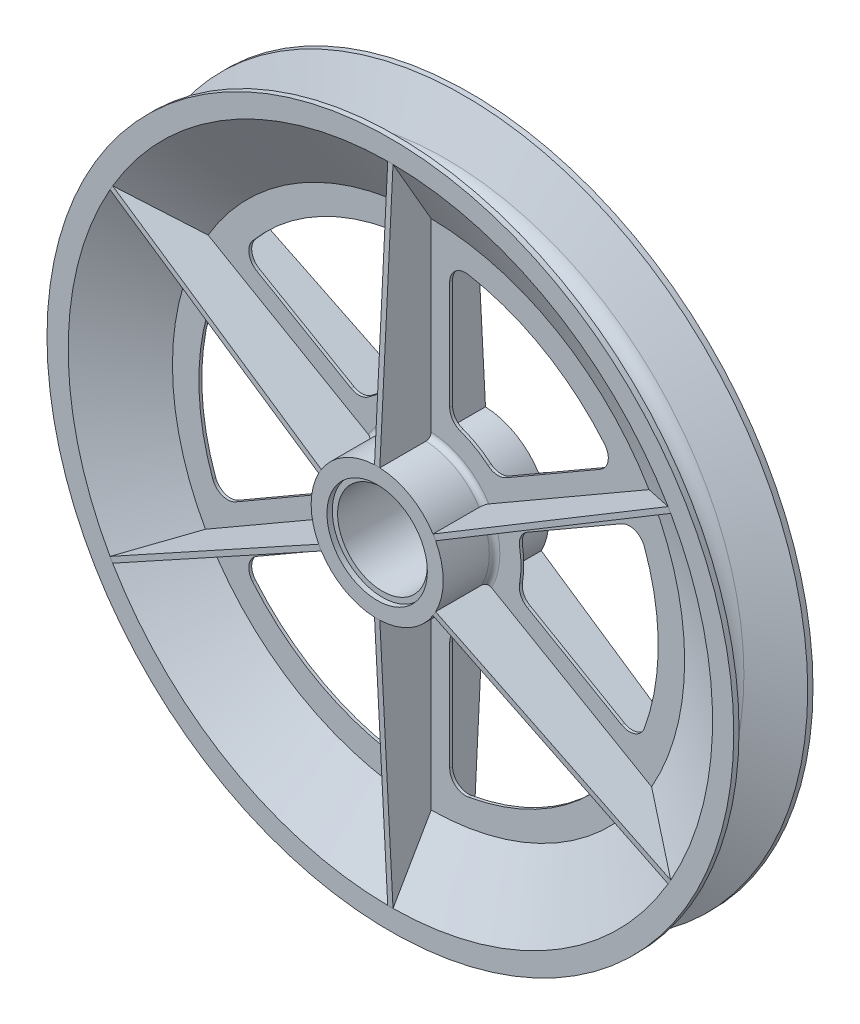
from build123d import *

# Parameters (mm, degrees)
SKETCH1_R            = 650
BOSS_EXTRUDE1_DEPTH  = 75
SKETCH2_R            = 480
CUT_EXTRUDE1_DEPTH   = 76
CUT_EXTRUDE1_TAPER   = -60
SKETCH3_R            = 125
BOSS_EXTRUDE2_DEPTH  = 100
SKETCH4_R            = 95
CUT_EXTRUDE2_DEPTH   = 10
SKETCH5_R            = 85
CUT_EXTRUDE3_DEPTH   = 201
SKETCH6_R            = 485
SKETCH6_R_2          = 85
BOSS_EXTRUDE3_DEPTH  = 2.75
FILLET1_R            = 10
CUT_EXTRUDE4_DEPTH   = 101
CIRPATTERN1_COUNT    = 6
BOSS_EXTRUDE4_DEPTH  = 5
CIRPATTERN2_COUNT    = 6
MIRROR3_COPY_1_DEPTH = 5
MIRROR3_COPY_2_DEPTH = 5
MIRROR3_COPY_3_DEPTH = 5
MIRROR3_COPY_4_DEPTH = 5
MIRROR3_COPY_5_DEPTH = 5
SCALE2_SCALE         = 0.035294118


with BuildPart() as part:
    # Sketch1 → Boss-Extrude1 (new body, symmetric)
    with BuildSketch(Plane.XY):
        Circle(SKETCH1_R)
    extrude(amount=BOSS_EXTRUDE1_DEPTH, both=True)

    # Sketch2 → Cut-Extrude1 (cut, through all)
    with BuildSketch(Plane.XY):
        Circle(SKETCH2_R)
    cut_extrude1 = extrude(amount=-CUT_EXTRUDE1_DEPTH, taper=CUT_EXTRUDE1_TAPER, mode=Mode.SUBTRACT)

    # Mirror1: Cut-Extrude1 across plane
    add(cut_extrude1.mirror(Plane.XY), mode=Mode.SUBTRACT)



with BuildPart() as body_2:
    # Sketch3 → Boss-Extrude2 (new body, symmetric)
    with BuildSketch(Plane.XY):
        Circle(SKETCH3_R)
    extrude(amount=BOSS_EXTRUDE2_DEPTH, both=True)

    # Sketch4 → Cut-Extrude2 (cut)
    with BuildSketch(Plane.XY.offset(100)):
        Circle(SKETCH4_R)
    cut_extrude2 = extrude(amount=-CUT_EXTRUDE2_DEPTH, mode=Mode.SUBTRACT)

    # Mirror2: Cut-Extrude2 across plane
    add(cut_extrude2.mirror(Plane.XY), mode=Mode.SUBTRACT)

    # Sketch5 → Cut-Extrude3 (cut, through all)
    with BuildSketch(Plane.XY.offset(100)):
        Circle(SKETCH5_R)
    extrude(amount=-CUT_EXTRUDE3_DEPTH, mode=Mode.SUBTRACT)


with BuildPart() as part_1:
    add(part.part)

    add(body_2.part)  # Boss-Extrude3 merges body 2
    # Sketch6 → Boss-Extrude3 (add, symmetric)
    with BuildSketch(Plane.XY):
        Circle(SKETCH6_R)
        Circle(SKETCH6_R_2, mode=Mode.SUBTRACT)
    extrude(amount=BOSS_EXTRUDE3_DEPTH, both=True)

    # Fillet1
    fillet1_edges = [part_1.edges().sort_by_distance(p)[0] for p in [
        (-125, 0, -2.75),
        (-125, 0, 2.75),
    ]]
    fillet(fillet1_edges, radius=FILLET1_R)

    # Sketch7 → Cut-Extrude4 (cut, symmetric)
    with BuildSketch(Plane.XY):
        with BuildLine():
            Line((40, 398.664268874), (40, 192.67848868))
            ThreePointArc((40, 192.67848868), (45.430536502, 175.463917427), (59.756097561, 164.481636678))
            ThreePointArc((59.756097561, 164.481636678), (87.5, 151.554445662), (112.567227039, 133.991116858))
            ThreePointArc((112.567227039, 133.991116858), (129.240941689, 127.075957432), (146.86446596, 130.980260491))
            Line((146.86446596, 130.980260491), (325.253384426, 233.973150588))
            ThreePointArc((325.253384426, 233.973150588), (339.795743882, 254.733855447), (333.248565111, 279.22102627))
            ThreePointArc((333.248565111, 279.22102627), (217.38156986, 376.515923627), (75.188219464, 428.212236296))
            ThreePointArc((75.188219464, 428.212236296), (50.70811808, 421.638674023), (40, 398.664268874))
        make_face()
    cut_extrude4 = extrude(amount=CUT_EXTRUDE4_DEPTH, both=True, mode=Mode.SUBTRACT)

    # CirPattern1: Cut-Extrude4 ×6 about axis
    cirpattern1_axis = Axis((0, 0, 0), (0, 0, 1))
    for i in range(1, CIRPATTERN1_COUNT):
        add(cut_extrude4.rotate(cirpattern1_axis, i * 360 / CIRPATTERN1_COUNT), mode=Mode.SUBTRACT)

    # Sketch8 → Boss-Extrude4 (add, symmetric)
    with BuildSketch(Plane(origin=(0, 0, 0), x_dir=(0, 0, -1), z_dir=(1, 0, 0))):
        Polygon((-75, 609.903810568), (-100, 125), (-100, 115), (-2.75, 115), (-2.75, 484.763139721), align=None)
    boss_extrude4 = extrude(amount=BOSS_EXTRUDE4_DEPTH, both=True)

    # CirPattern2: Boss-Extrude4 ×6 about axis
    cirpattern2_axis = Axis((0, 0, 0), (0, 0, 1))
    for i in range(1, CIRPATTERN2_COUNT):
        add(boss_extrude4.rotate(cirpattern2_axis, i * 360 / CIRPATTERN2_COUNT))

    # Mirror3: Boss-Extrude4 across plane
    add(boss_extrude4.mirror(Plane.XY))

    # Mirror3 copy 1 sketch → Mirror3 copy 1 (add, symmetric)
    with BuildSketch(Plane(origin=(0, 0, 0), x_dir=(0, 0, 1), z_dir=(0.5, 0.866025404, 0))):
        Polygon((-75, -609.903810568), (-100, -125), (-100, -115), (-2.75, -115), (-2.75, -484.763139721), align=None)
    extrude(amount=MIRROR3_COPY_1_DEPTH, both=True)

    # Mirror3 copy 2 sketch → Mirror3 copy 2 (add, symmetric)
    with BuildSketch(Plane(origin=(0, 0, 0), x_dir=(0, 0, 1), z_dir=(-0.5, 0.866025404, 0))):
        Polygon((-75, -609.903810568), (-100, -125), (-100, -115), (-2.75, -115), (-2.75, -484.763139721), align=None)
    extrude(amount=MIRROR3_COPY_2_DEPTH, both=True)

    # Mirror3 copy 3 sketch → Mirror3 copy 3 (add, symmetric)
    with BuildSketch(Plane.ZY):
        Polygon((-75, -609.903810568), (-100, -125), (-100, -115), (-2.75, -115), (-2.75, -484.763139721), align=None)
    extrude(amount=MIRROR3_COPY_3_DEPTH, both=True)

    # Mirror3 copy 4 sketch → Mirror3 copy 4 (add, symmetric)
    with BuildSketch(Plane(origin=(0, 0, 0), x_dir=(0, 0, 1), z_dir=(-0.5, -0.866025404, 0))):
        Polygon((-75, -609.903810568), (-100, -125), (-100, -115), (-2.75, -115), (-2.75, -484.763139721), align=None)
    extrude(amount=MIRROR3_COPY_4_DEPTH, both=True)

    # Mirror3 copy 5 sketch → Mirror3 copy 5 (add, symmetric)
    with BuildSketch(Plane(origin=(0, 0, 0), x_dir=(0, 0, 1), z_dir=(0.5, -0.866025404, 0))):
        Polygon((-75, -609.903810568), (-100, -125), (-100, -115), (-2.75, -115), (-2.75, -484.763139721), align=None)
    extrude(amount=MIRROR3_COPY_5_DEPTH, both=True)

    # Sketch9 → Cut-Revolve1 (revolve, cut)
    with BuildSketch(Plane(origin=(0, 0, 0), x_dir=(0, 0, -1), z_dir=(1, 0, 0))):
        with BuildLine():
            Line((-65, 650), (-28.725643175, 563.839193177))
            ThreePointArc((-28.725643175, 563.839193177), (0.766799772, 544.37881752), (30.032111832, 564.179118571))
            Line((30.032111832, 564.179118571), (65, 650))
            Line((65, 650), (-65, 650))
        make_face()
    revolve(axis=Axis((0, 0, 0), (0, 0, 1)), mode=Mode.SUBTRACT)


with BuildPart() as part_2:
    # Scale2: scaled about (7e-09, 1.2e-08, 0.265004063)
    add(part_1.part.scale(SCALE2_SCALE).moved(Location((7e-09, 1.2e-08, 0.255650978))))


solid = part_2.part
